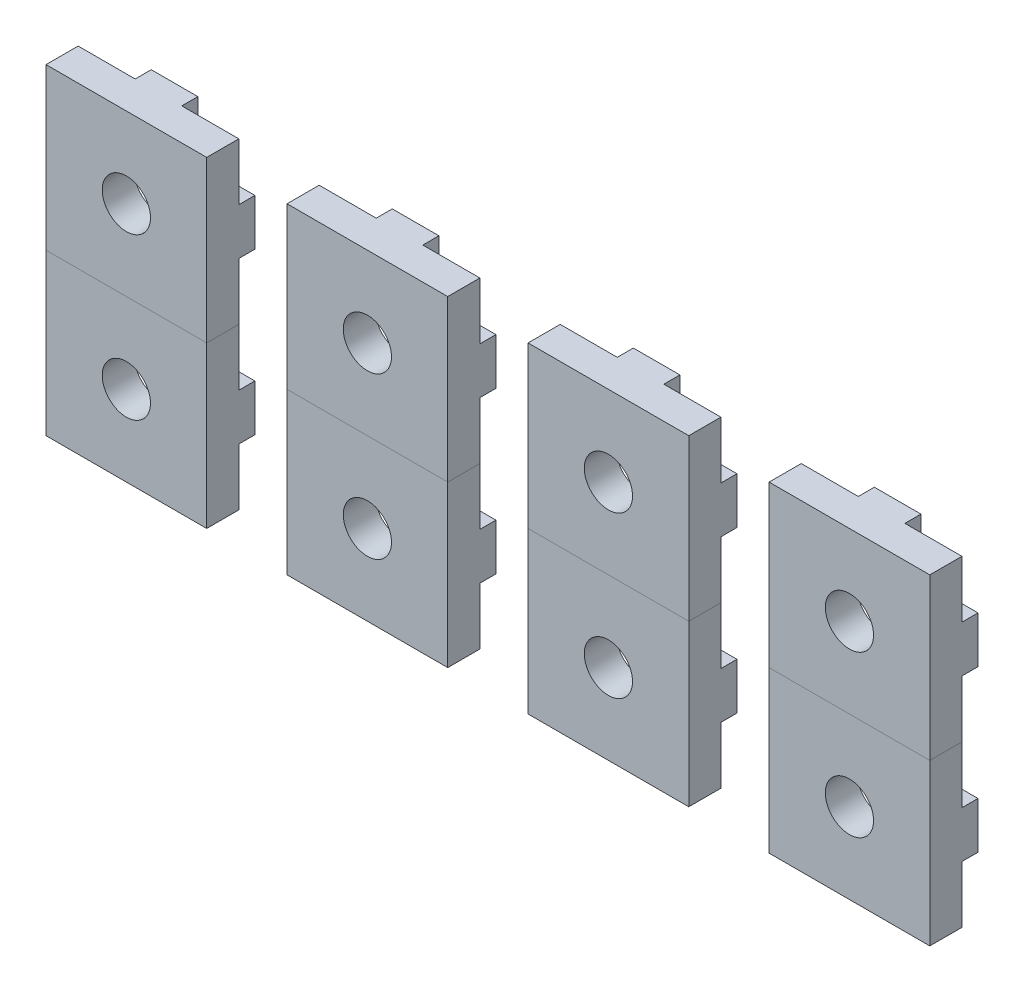
from build123d import *

# Parameters (mm, degrees)
SKETCH1_W                = 10
SKETCH1_H                = 10
SKETCH1_R                = 1.5
MAIN_DEPTH               = 2
ANTIROTATIONSYSTEM_DEPTH = 1
CIRPATTERN1_COUNT        = 4
LPATTERN1_COUNT          = 2
LPATTERN1_PITCH          = 10
LPATTERN2_COUNT          = 4
LPATTERN2_PITCH          = 15


with BuildPart() as part:
    # Sketch1 → Main (new body)
    with BuildSketch(Plane.XY):
        Rectangle(SKETCH1_W, SKETCH1_H)
        Circle(SKETCH1_R, mode=Mode.SUBTRACT)
    extrude(amount=MAIN_DEPTH)

    # Sketch2 → AntiRotationSystem (add)
    with BuildSketch(Plane(origin=(0, 0, 0), x_dir=(-1, 0, 0), z_dir=(0, 0, -1))):
        Polygon((-5, 1.45), (-3.9, 1.45), (-3.9, 3), (-2.1, 0.95), (-2.1, -0.95), (-3.9, -3), (-3.9, -1.45), (-5, -1.45), align=None)
    antirotationsystem = extrude(amount=ANTIROTATIONSYSTEM_DEPTH)

    # CirPattern1: AntiRotationSystem ×4 about axis
    cirpattern1_axis = Axis((0, 0, 0), (0, 0, 1))
    for i in range(1, CIRPATTERN1_COUNT):
        add(antirotationsystem.rotate(cirpattern1_axis, i * 360 / CIRPATTERN1_COUNT))


with BuildPart() as lpattern1_1:
    # LPattern1: pattern copy
    add(part.part.moved(Location(Vector(0, -1, 0) * (1 * LPATTERN1_PITCH))))


with BuildPart() as lpattern2_1:
    # LPattern2: pattern copy
    add(lpattern1_1.part.moved(Location(Vector(-1, 0, 0) * (1 * LPATTERN2_PITCH))))


with BuildPart() as lpattern2_2:
    # LPattern2: pattern copy
    add(lpattern1_1.part.moved(Location(Vector(-1, 0, 0) * (2 * LPATTERN2_PITCH))))


with BuildPart() as lpattern2_3:
    # LPattern2: pattern copy
    add(lpattern1_1.part.moved(Location(Vector(-1, 0, 0) * (3 * LPATTERN2_PITCH))))


with BuildPart() as lpattern2_4:
    # LPattern2: pattern copy
    add(part.part.moved(Location(Vector(-1, 0, 0) * (1 * LPATTERN2_PITCH))))


with BuildPart() as lpattern2_5:
    # LPattern2: pattern copy
    add(part.part.moved(Location(Vector(-1, 0, 0) * (2 * LPATTERN2_PITCH))))


with BuildPart() as lpattern2_6:
    # LPattern2: pattern copy
    add(part.part.moved(Location(Vector(-1, 0, 0) * (3 * LPATTERN2_PITCH))))


solid = Compound([part.part, lpattern1_1.part, lpattern2_1.part, lpattern2_2.part, lpattern2_3.part, lpattern2_4.part, lpattern2_5.part, lpattern2_6.part])
